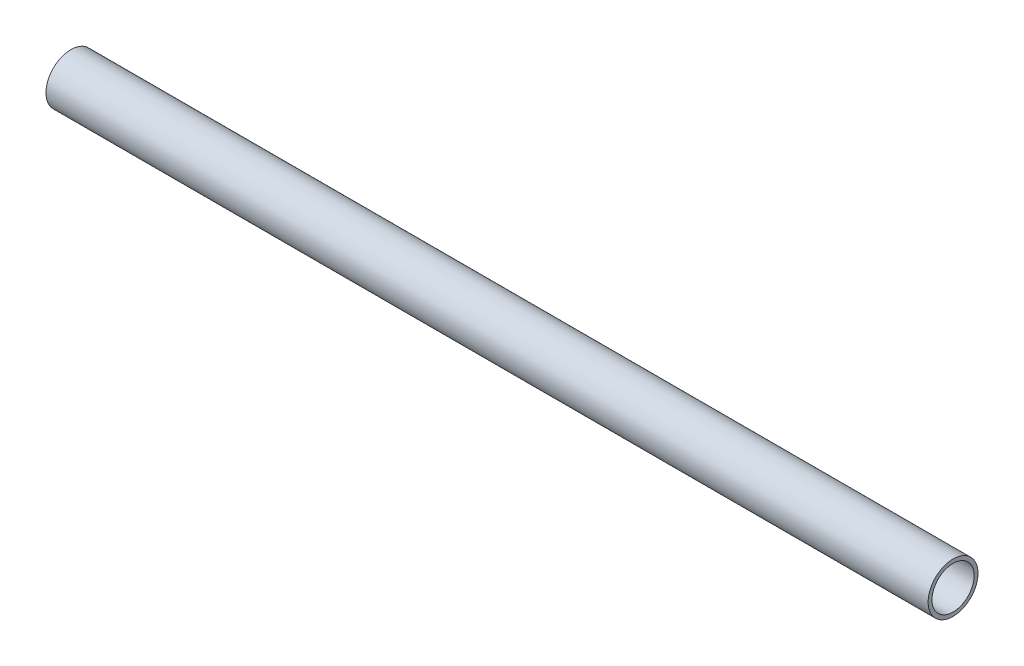
from build123d import *

# Parameters (mm, degrees)
SKETCH_1_R          = 13
SKETCH_1_R_2        = 11
EXTRUDE_1_DEPTH     = 460
SKETCH_2_R          = 2
SKETCH_2_R_2        = 2.5
CUT_EXTRUDE_1_DEPTH = 14
SKETCH_4_R          = 1.5
CUT_EXTRUDE_2_DEPTH = 14.0000001


with BuildPart() as part:
    # 草图1 → 凸台-拉伸1 (new body)
    with BuildSketch(Plane(origin=(0, 0, 0), x_dir=(0, 0, -1), z_dir=(1, 0, 0))):
        Circle(SKETCH_1_R)
        Circle(SKETCH_1_R_2, mode=Mode.SUBTRACT)
    extrude(amount=EXTRUDE_1_DEPTH)

    # 草图2 → 切除-拉伸1 (cut, through all)
    with BuildSketch(Plane.XY):
        with Locations((21, 0)):
            Circle(SKETCH_2_R)
        with Locations((445, 0)):
            Circle(SKETCH_2_R_2)
    extrude(amount=-CUT_EXTRUDE_1_DEPTH, mode=Mode.SUBTRACT)

    # 草图4 → 切除-拉伸2 (cut, through all)
    with BuildSketch(Plane(origin=(0, 0, 0), x_dir=(1, 0, 0), z_dir=(0, 1, 0))):
        with Locations((12.5, 0)):
            Circle(SKETCH_4_R)
        with Locations((441.5, 0)):
            Circle(SKETCH_4_R)
    extrude(amount=-CUT_EXTRUDE_2_DEPTH, mode=Mode.SUBTRACT)


solid = part.part
